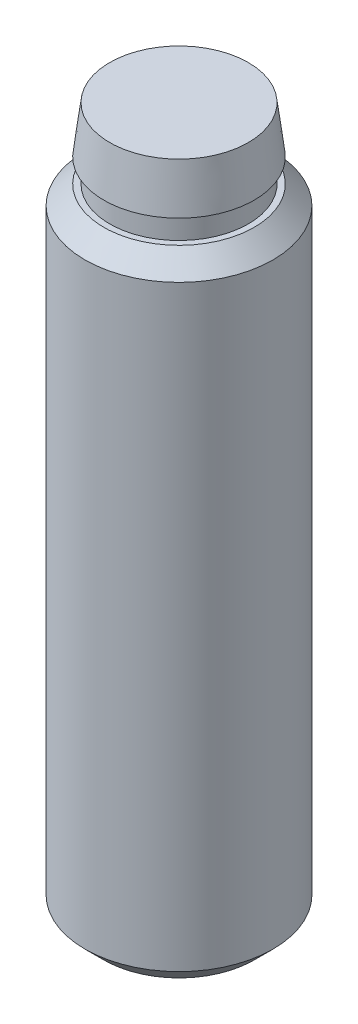
from build123d import *

# Parameters (mm, degrees)
CHANFREIN1_SIZE = 0.8


with BuildPart() as part:
    # Esquisse1 → Base-Révolution (revolve)
    with BuildSketch(Plane.XY, mode=Mode.PRIVATE) as base_r_volution_sk:
        Polygon((2.95, 28), (3.2, 28), (2.95, 30), (0, 30), (0, 0), (4, 0), (4, 26.2), (3.2, 27), (2.95, 27), align=None)
    revolve(base_r_volution_sk.sketch.rotate(Axis((0, -1.36682243, 0), (0, 1, 0)), 90), axis=Axis((0, -1.36682243, 0), (0, 1, 0)))  # turned: the seam where the file's is

    # Chanfrein1
    chanfrein1_edges = [part.edges().sort_by_distance(p)[0] for p in [
        (0, 0, 4),
    ]]
    chamfer(chanfrein1_edges, length=CHANFREIN1_SIZE)


solid = part.part
